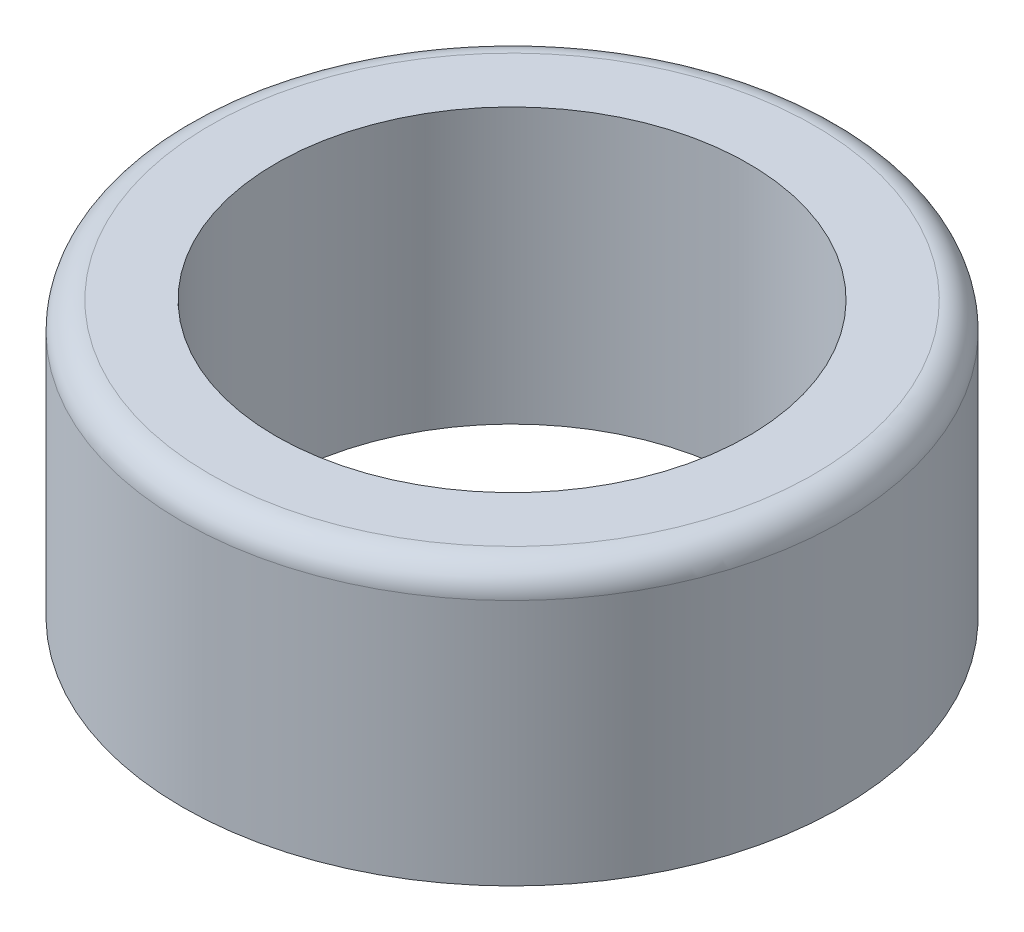
from build123d import *

# Parameters (mm, degrees)
SKETCH_1_R      = 12
SKETCH_1_R_2    = 8.6
EXTRUDE_1_DEPTH = 10
FILLET_1_R      = 1


with BuildPart() as part:
    # 草图1 → 凸台-拉伸1 (new body)
    with BuildSketch(Plane(origin=(0, 0, 0), x_dir=(1, 0, 0), z_dir=(0, 1, 0))):
        Circle(SKETCH_1_R)
        Circle(SKETCH_1_R_2, mode=Mode.SUBTRACT)
    extrude(amount=EXTRUDE_1_DEPTH)

    # 圆角1
    fillet_1_edges = [part.edges().sort_by_distance(p)[0] for p in [
        (-12, 10, 0),
    ]]
    fillet(fillet_1_edges, radius=FILLET_1_R)


solid = part.part
